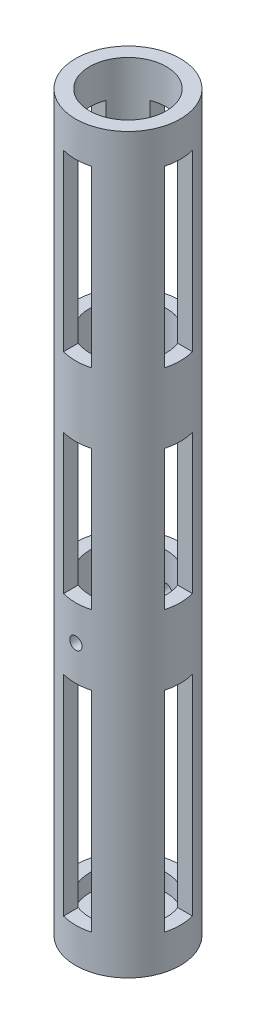
from build123d import *

# Parameters (mm, degrees)
SKETCH1_R               = 19.05
SKETCH1_R_2             = 13.97
BOSS_EXTRUDE1_DEPTH     = 266.7
SKETCH2_R               = 13.97
BOSS_EXTRUDE2_DEPTH     = 6.35
SKETCH3_R               = 2.2479
CUT_EXTRUDE1_DEPTH      = 3.54
CUT_EXTRUDE1_DEPTH_BACK = 36.56
SKETCH5_W               = 10.16
SKETCH5_H               = 76.2
SKETCH5_H_2             = 50.8
SKETCH5_H_3             = 63.5
CUT_EXTRUDE5_DEPTH      = 20.0500001
CUT_EXTRUDE5_DEPTH_BACK = 20.0500001
SKETCH8_W               = 10.16
SKETCH8_H               = 76.2
SKETCH8_H_2             = 50.8
SKETCH8_H_3             = 63.5
CUT_EXTRUDE6_DEPTH      = 20.050000101
CUT_EXTRUDE6_DEPTH_BACK = 20.050000101
SKETCH7_R               = 6.35
CUT_EXTRUDE4_DEPTH      = 7.3500001


with BuildPart() as part:
    # Sketch1 → Boss-Extrude1 (new body)
    with BuildSketch(Plane(origin=(0, 0, 0), x_dir=(1, 0, 0), z_dir=(0, 1, 0))):
        Circle(SKETCH1_R)
        Circle(SKETCH1_R_2, mode=Mode.SUBTRACT)
    extrude(amount=BOSS_EXTRUDE1_DEPTH)

    # Sketch2 → Boss-Extrude2 (add)
    with BuildSketch(Plane.XZ):
        Circle(SKETCH2_R)
    extrude(amount=-BOSS_EXTRUDE2_DEPTH)

    # Sketch3 → Cut-Extrude1 (cut, two sides)
    with BuildSketch(Plane.XY.offset(16.51)) as cut_extrude1_sk:
        with Locations((0, 101.6)):
            Circle(SKETCH3_R)
    extrude(amount=CUT_EXTRUDE1_DEPTH, mode=Mode.SUBTRACT)
    extrude(cut_extrude1_sk.sketch, amount=-CUT_EXTRUDE1_DEPTH_BACK, mode=Mode.SUBTRACT)

    # Sketch5 → Cut-Extrude5 (cut, two sides)
    with BuildSketch(Plane(origin=(0, 0, 0), x_dir=(0, 0, -1), z_dir=(1, 0, 0))) as cut_extrude5_sk:
        with Locations((0, 50.8)):
            Rectangle(SKETCH5_W, SKETCH5_H)
        with Locations((0, 139.7)):
            Rectangle(SKETCH5_W, SKETCH5_H_2)
        with Locations((0, 222.25)):
            Rectangle(SKETCH5_W, SKETCH5_H_3)
    extrude(amount=CUT_EXTRUDE5_DEPTH, mode=Mode.SUBTRACT)
    extrude(cut_extrude5_sk.sketch, amount=-CUT_EXTRUDE5_DEPTH_BACK, mode=Mode.SUBTRACT)

    # Sketch8 → Cut-Extrude6 (cut, two sides)
    with BuildSketch(Plane.XY) as cut_extrude6_sk:
        with Locations((0, 50.8)):
            Rectangle(SKETCH8_W, SKETCH8_H)
        with Locations((0, 139.7)):
            Rectangle(SKETCH8_W, SKETCH8_H_2)
        with Locations((0, 222.25)):
            Rectangle(SKETCH8_W, SKETCH8_H_3)
    extrude(amount=CUT_EXTRUDE6_DEPTH, mode=Mode.SUBTRACT)
    extrude(cut_extrude6_sk.sketch, amount=-CUT_EXTRUDE6_DEPTH_BACK, mode=Mode.SUBTRACT)

    # Sketch7 → Cut-Extrude4 (cut, through all)
    with BuildSketch(Plane(origin=(0, 6.35, 0), x_dir=(1, 0, 0), z_dir=(0, 1, 0))):
        Circle(SKETCH7_R)
    extrude(amount=-CUT_EXTRUDE4_DEPTH, mode=Mode.SUBTRACT)


solid = part.part
